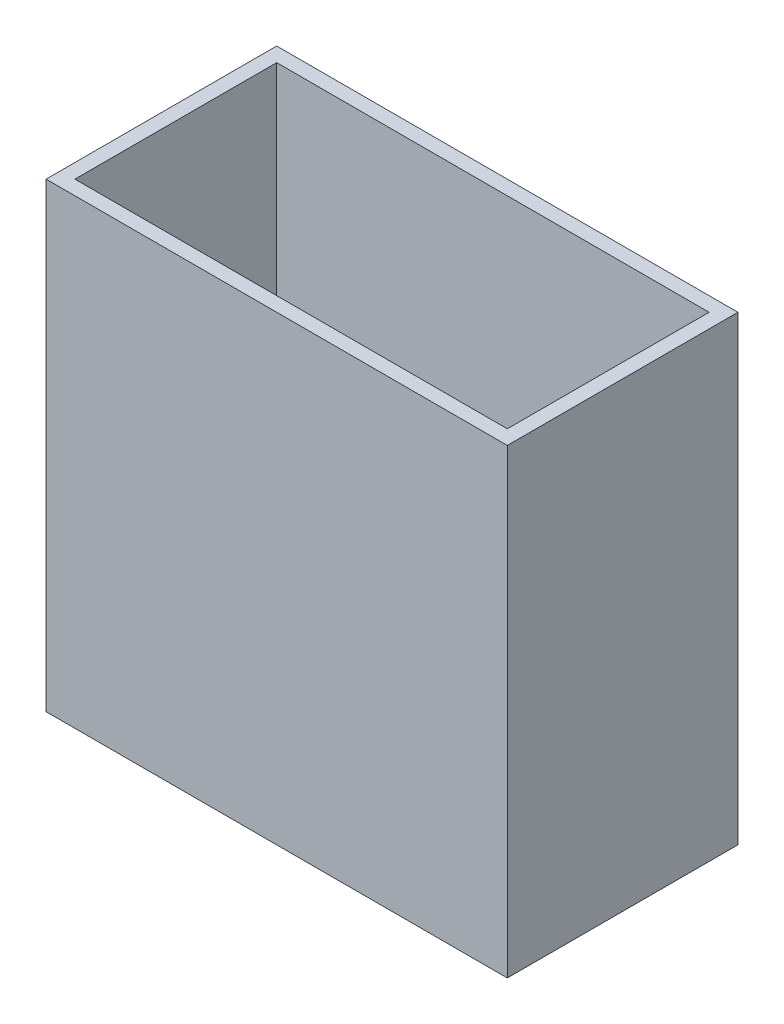
from build123d import *

# Parameters (mm, degrees)
SKETCH1_W           = 50.8
SKETCH1_H           = 25.4
SKETCH1_W_2         = 47.625
SKETCH1_H_2         = 22.225
BOSS_EXTRUDE1_DEPTH = 50.8


with BuildPart() as part:
    # Sketch1 → Boss-Extrude1 (new body)
    with BuildSketch(Plane(origin=(0, 0, 0), x_dir=(1, 0, 0), z_dir=(0, 1, 0))):
        with Locations((-1.188304094, -1.039766082)):
            Rectangle(SKETCH1_W, SKETCH1_H)
        with Locations((-1.188304094, -1.039766082)):
            Rectangle(SKETCH1_W_2, SKETCH1_H_2, mode=Mode.SUBTRACT)
    extrude(amount=BOSS_EXTRUDE1_DEPTH)


solid = part.part
